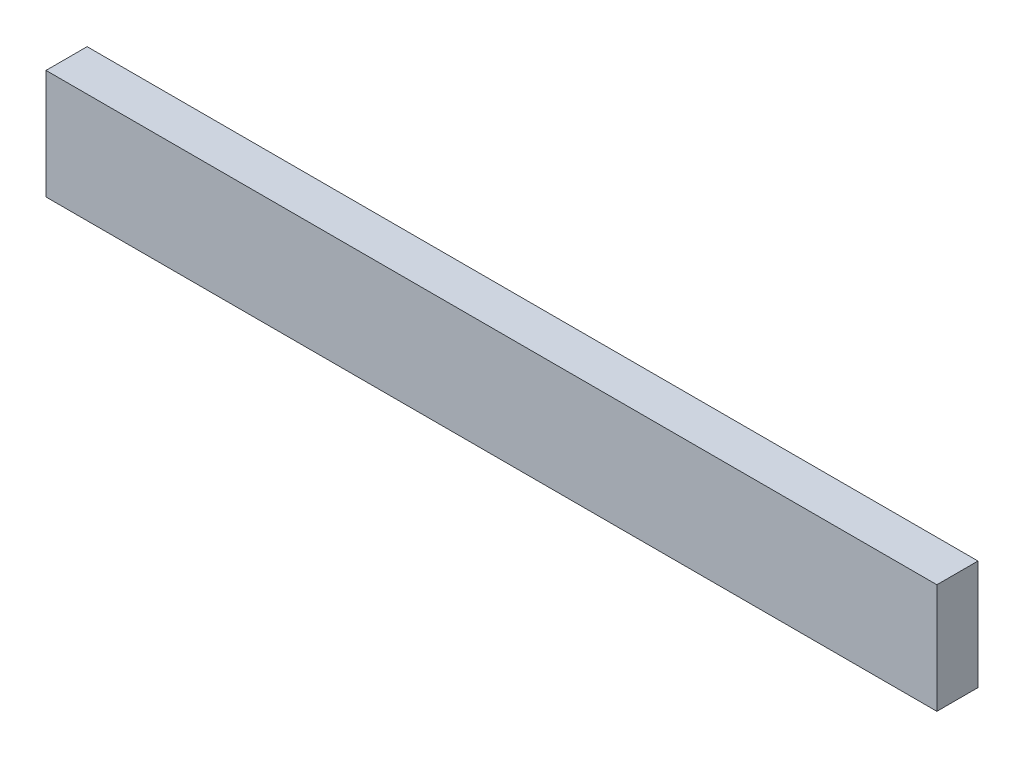
from build123d import *

# Parameters (mm, degrees)
SKETCH1_W           = 650
SKETCH1_H           = 80
BOSS_EXTRUDE1_DEPTH = 30


with BuildPart() as part:
    # Sketch1 → Boss-Extrude1 (new body)
    with BuildSketch(Plane.XY):
        Rectangle(SKETCH1_W, SKETCH1_H)
    extrude(amount=BOSS_EXTRUDE1_DEPTH)


solid = part.part
